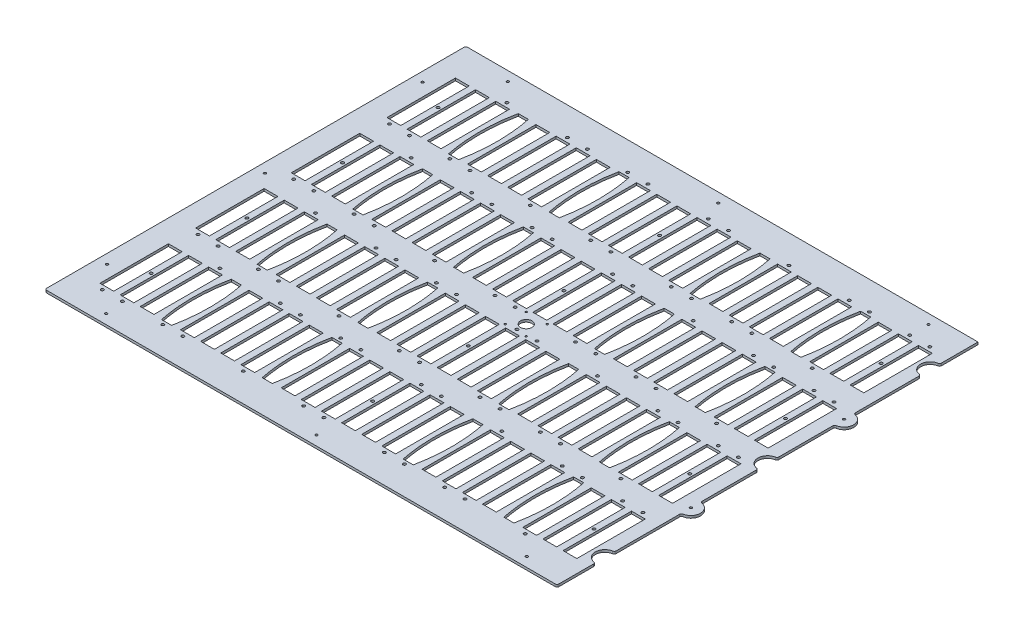
from build123d import *

# Parameters (mm, degrees)
BOSS_EXTRUDE1_DEPTH          = 3.175
SKETCH17_W                   = 18.288
SKETCH17_H                   = 90.932
CUT_EXTRUDE5_DEPTH           = 4.175
F_25_0_1495_DIAMETER_HOLE1_D = 3.7973
FILLET1_R                    = 2.54
F_6_CLEARANCE_HOLE1_D        = 3.7973
F_2_CLEARANCE_HOLE1_D        = 2.4384
SKETCH20_R                   = 7.62
CUT_EXTRUDE6_DEPTH           = 4.175
F_1_8_0_125_DIAMETER_HOLE1_D = 3.175
CUT_EXTRUDE7_DEPTH           = 4.175


with BuildPart() as part:
    # Sketch1 → Boss-Extrude1 (new body)
    with BuildSketch(Plane(origin=(0, 0, 0), x_dir=(1, 0, 0), z_dir=(0, 1, 0))):
        with BuildLine():
            Line((-340.1822, -279.5524), (340.1822, -279.5524))
            Line((340.1822, -279.5524), (340.1822, -228.7524))
            ThreePointArc((340.1822, -228.7524), (327.4822, -216.0524), (340.1822, -203.3524))
            Line((340.1822, -203.3524), (340.1822, -114.4524))
            ThreePointArc((340.1822, -114.4524), (352.8822, -101.7524), (340.1822, -89.0524))
            Line((340.1822, -89.0524), (340.1822, -12.7))
            ThreePointArc((340.1822, -12.7), (327.4822, 0), (340.1822, 12.7))
            Line((340.1822, 12.7), (340.1822, 89.0524))
            ThreePointArc((340.1822, 89.0524), (352.8822, 101.7524), (340.1822, 114.4524))
            Line((340.1822, 114.4524), (340.1822, 203.3524))
            ThreePointArc((340.1822, 203.3524), (327.4822, 216.0524), (340.1822, 228.7524))
            Line((340.1822, 228.7524), (340.1822, 279.5524))
            Line((340.1822, 279.5524), (-340.1822, 279.5524))
            Line((-340.1822, 279.5524), (-340.1822, -279.5524))
        make_face()
    extrude(amount=BOSS_EXTRUDE1_DEPTH)

    # Sketch17 → Cut-Extrude5 (cut, through all)
    with BuildSketch(Plane(origin=(0, 3.175, 0), x_dir=(1, 0, 0), z_dir=(0, 1, 0))):
        with Locations((-274.627008696, 190.6524)):
            Rectangle(SKETCH17_W, SKETCH17_H)
        with Locations((-301.371, 190.6524)):
            Rectangle(SKETCH17_W, SKETCH17_H)
        with Locations((-247.883017391, 190.6524)):
            Rectangle(SKETCH17_W, SKETCH17_H)
        with Locations((-194.395034783, 190.6524)):
            Rectangle(SKETCH17_W, SKETCH17_H)
        with Locations((-167.651043478, 190.6524)):
            Rectangle(SKETCH17_W, SKETCH17_H)
        with Locations((-140.907052174, 190.6524)):
            Rectangle(SKETCH17_W, SKETCH17_H)
        with Locations((-114.16306087, 190.6524)):
            Rectangle(SKETCH17_W, SKETCH17_H)
        with Locations((-60.675078261, 190.6524)):
            Rectangle(SKETCH17_W, SKETCH17_H)
        with Locations((-33.931086957, 190.6524)):
            Rectangle(SKETCH17_W, SKETCH17_H)
        with Locations((-7.187095652, 190.6524)):
            Rectangle(SKETCH17_W, SKETCH17_H)
        with Locations((19.556895652, 190.6524)):
            Rectangle(SKETCH17_W, SKETCH17_H)
        with Locations((46.300886957, 190.6524)):
            Rectangle(SKETCH17_W, SKETCH17_H)
        with Locations((73.044878261, 190.6524)):
            Rectangle(SKETCH17_W, SKETCH17_H)
        with Locations((126.53286087, 190.6524)):
            Rectangle(SKETCH17_W, SKETCH17_H)
        with Locations((153.276852174, 190.6524)):
            Rectangle(SKETCH17_W, SKETCH17_H)
        with Locations((180.020843478, 190.6524)):
            Rectangle(SKETCH17_W, SKETCH17_H)
        with Locations((206.764834783, 190.6524)):
            Rectangle(SKETCH17_W, SKETCH17_H)
        with Locations((260.252817391, 190.6524)):
            Rectangle(SKETCH17_W, SKETCH17_H)
        with Locations((286.996808696, 190.6524)):
            Rectangle(SKETCH17_W, SKETCH17_H)
        with Locations((313.7408, 190.6524)):
            Rectangle(SKETCH17_W, SKETCH17_H)
        with Locations((-274.627008696, 63.5762)):
            Rectangle(SKETCH17_W, SKETCH17_H)
        with Locations((-247.883017391, 63.5762)):
            Rectangle(SKETCH17_W, SKETCH17_H)
        with Locations((-194.395034783, 63.5762)):
            Rectangle(SKETCH17_W, SKETCH17_H)
        with Locations((-167.651043478, 63.5762)):
            Rectangle(SKETCH17_W, SKETCH17_H)
        with Locations((-140.907052174, 63.5762)):
            Rectangle(SKETCH17_W, SKETCH17_H)
        with Locations((-114.16306087, 63.5762)):
            Rectangle(SKETCH17_W, SKETCH17_H)
        with Locations((-60.675078261, 63.5762)):
            Rectangle(SKETCH17_W, SKETCH17_H)
        with Locations((-33.931086957, 63.5762)):
            Rectangle(SKETCH17_W, SKETCH17_H)
        with Locations((-7.187095652, 63.5762)):
            Rectangle(SKETCH17_W, SKETCH17_H)
        with Locations((19.556895652, 63.5762)):
            Rectangle(SKETCH17_W, SKETCH17_H)
        with Locations((46.300886957, 63.5762)):
            Rectangle(SKETCH17_W, SKETCH17_H)
        with Locations((73.044878261, 63.5762)):
            Rectangle(SKETCH17_W, SKETCH17_H)
        with Locations((126.53286087, 63.5762)):
            Rectangle(SKETCH17_W, SKETCH17_H)
        with Locations((153.276852174, 63.5762)):
            Rectangle(SKETCH17_W, SKETCH17_H)
        with Locations((180.020843478, 63.5762)):
            Rectangle(SKETCH17_W, SKETCH17_H)
        with Locations((206.764834783, 63.5762)):
            Rectangle(SKETCH17_W, SKETCH17_H)
        with Locations((260.252817391, 63.5762)):
            Rectangle(SKETCH17_W, SKETCH17_H)
        with Locations((286.996808696, 63.5762)):
            Rectangle(SKETCH17_W, SKETCH17_H)
        with Locations((313.7408, 63.5762)):
            Rectangle(SKETCH17_W, SKETCH17_H)
        with Locations((-274.627008696, -63.5)):
            Rectangle(SKETCH17_W, SKETCH17_H)
        with Locations((-247.883017391, -63.5)):
            Rectangle(SKETCH17_W, SKETCH17_H)
        with Locations((-194.395034783, -63.5)):
            Rectangle(SKETCH17_W, SKETCH17_H)
        with Locations((-167.651043478, -63.5)):
            Rectangle(SKETCH17_W, SKETCH17_H)
        with Locations((-140.907052174, -63.5)):
            Rectangle(SKETCH17_W, SKETCH17_H)
        with Locations((-114.16306087, -63.5)):
            Rectangle(SKETCH17_W, SKETCH17_H)
        with Locations((-60.675078261, -63.5)):
            Rectangle(SKETCH17_W, SKETCH17_H)
        with Locations((-33.931086957, -63.5)):
            Rectangle(SKETCH17_W, SKETCH17_H)
        with Locations((-7.187095652, -63.5)):
            Rectangle(SKETCH17_W, SKETCH17_H)
        with Locations((19.556895652, -63.5)):
            Rectangle(SKETCH17_W, SKETCH17_H)
        with Locations((46.300886957, -63.5)):
            Rectangle(SKETCH17_W, SKETCH17_H)
        with Locations((73.044878261, -63.5)):
            Rectangle(SKETCH17_W, SKETCH17_H)
        with Locations((126.53286087, -63.5)):
            Rectangle(SKETCH17_W, SKETCH17_H)
        with Locations((153.276852174, -63.5)):
            Rectangle(SKETCH17_W, SKETCH17_H)
        with Locations((180.020843478, -63.5)):
            Rectangle(SKETCH17_W, SKETCH17_H)
        with Locations((206.764834783, -63.5)):
            Rectangle(SKETCH17_W, SKETCH17_H)
        with Locations((260.252817391, -63.5)):
            Rectangle(SKETCH17_W, SKETCH17_H)
        with Locations((286.996808696, -63.5)):
            Rectangle(SKETCH17_W, SKETCH17_H)
        with Locations((313.7408, -63.5)):
            Rectangle(SKETCH17_W, SKETCH17_H)
        with Locations((-274.627008696, -190.5762)):
            Rectangle(SKETCH17_W, SKETCH17_H)
        with Locations((-247.883017391, -190.5762)):
            Rectangle(SKETCH17_W, SKETCH17_H)
        with Locations((-194.395034783, -190.5762)):
            Rectangle(SKETCH17_W, SKETCH17_H)
        with Locations((-167.651043478, -190.5762)):
            Rectangle(SKETCH17_W, SKETCH17_H)
        with Locations((-140.907052174, -190.5762)):
            Rectangle(SKETCH17_W, SKETCH17_H)
        with Locations((-114.16306087, -190.5762)):
            Rectangle(SKETCH17_W, SKETCH17_H)
        with Locations((-60.675078261, -190.5762)):
            Rectangle(SKETCH17_W, SKETCH17_H)
        with Locations((-33.931086957, -190.5762)):
            Rectangle(SKETCH17_W, SKETCH17_H)
        with Locations((-7.187095652, -190.5762)):
            Rectangle(SKETCH17_W, SKETCH17_H)
        with Locations((19.556895652, -190.5762)):
            Rectangle(SKETCH17_W, SKETCH17_H)
        with Locations((46.300886957, -190.5762)):
            Rectangle(SKETCH17_W, SKETCH17_H)
        with Locations((73.044878261, -190.5762)):
            Rectangle(SKETCH17_W, SKETCH17_H)
        with Locations((126.53286087, -190.5762)):
            Rectangle(SKETCH17_W, SKETCH17_H)
        with Locations((153.276852174, -190.5762)):
            Rectangle(SKETCH17_W, SKETCH17_H)
        with Locations((180.020843478, -190.5762)):
            Rectangle(SKETCH17_W, SKETCH17_H)
        with Locations((206.764834783, -190.5762)):
            Rectangle(SKETCH17_W, SKETCH17_H)
        with Locations((260.252817391, -190.5762)):
            Rectangle(SKETCH17_W, SKETCH17_H)
        with Locations((286.996808696, -190.5762)):
            Rectangle(SKETCH17_W, SKETCH17_H)
        with Locations((313.7408, -190.5762)):
            Rectangle(SKETCH17_W, SKETCH17_H)
        with Locations((-301.371, 63.5762)):
            Rectangle(SKETCH17_W, SKETCH17_H)
        with Locations((-301.371, -63.5)):
            Rectangle(SKETCH17_W, SKETCH17_H)
        with Locations((-301.371, -190.5762)):
            Rectangle(SKETCH17_W, SKETCH17_H)
    extrude(amount=-CUT_EXTRUDE5_DEPTH, mode=Mode.SUBTRACT)

    # #25 (0.1495) Diameter Hole1 (through all)
    with Locations(Plane(origin=(0, 3.175, 0), x_dir=(1, 0, 0), z_dir=(0, 1, 0))):
        with Locations((-301.523398222, 139.3444), (313.7408, -139.2682), (286.990182686, -139.2682), (260.239565372, -241.8842), (233.488948058, -139.2682), (206.738330744, -139.2682), (179.98771343, -241.8842), (153.237096116, -241.8842), (126.486478802, -139.2682), (99.735861488, -241.8842), (72.985244174, -241.8842), (46.23462686, -139.2682), (19.484009546, -139.2682), (-7.266607768, -241.8842), (-34.017225082, -241.8842), (-60.767842396, -139.2682), (-87.51845971, -139.2682), (-114.269077024, -241.8842), (-141.019694338, -139.2682), (-167.770311652, -139.2682), (-194.520928966, -241.8842), (-221.27154628, -241.8842), (-248.022163594, -139.2682), (-274.772780908, -241.8842), (-301.523398222, -241.8842), (313.7408, -12.192), (286.990182686, -12.192), (260.239565372, -114.808), (233.488948058, -12.192), (206.738330744, -12.192), (179.98771343, -114.808), (153.237096116, -114.808), (126.486478802, -12.192), (99.735861488, -114.808), (72.985244174, -114.808), (46.23462686, -12.192), (19.484009546, -12.192), (-7.266607768, -114.808), (-34.017225082, -114.808), (-60.767842396, -12.192), (-87.51845971, -12.192), (-114.269077024, -114.808), (-141.019694338, -12.192), (-167.770311652, -12.192), (-194.520928966, -114.808), (-221.27154628, -114.808), (-248.022163594, -12.192), (-274.772780908, -114.808), (-301.523398222, -114.808), (313.7408, 114.8842), (286.990182686, 114.8842), (260.239565372, 12.2682), (233.488948058, 114.8842), (206.738330744, 114.8842), (179.98771343, 12.2682), (153.237096116, 12.2682), (126.486478802, 114.8842), (99.735861488, 12.2682), (72.985244174, 12.2682), (46.23462686, 114.8842), (19.484009546, 114.8842), (-7.266607768, 12.2682), (-34.017225082, 12.2682), (-60.767842396, 114.8842), (-87.51845971, 114.8842), (-114.269077024, 12.2682), (-141.019694338, 114.8842), (-167.770311652, 114.8842), (-194.520928966, 12.2682), (-221.27154628, 12.2682), (-248.022163594, 114.8842), (-274.772780908, 12.2682), (-301.523398222, 12.2682), (313.7408, 241.9604), (286.990182686, 241.9604), (260.239565372, 139.3444), (233.488948058, 241.9604), (206.738330744, 241.9604), (179.98771343, 139.3444), (153.237096116, 139.3444), (126.486478802, 241.9604), (99.735861488, 139.3444), (72.985244174, 139.3444), (46.23462686, 241.9604), (19.484009546, 241.9604), (-7.266607768, 139.3444), (-34.017225082, 139.3444), (-60.767842396, 241.9604), (-87.51845971, 241.9604), (-114.269077024, 139.3444), (-141.019694338, 241.9604), (-167.770311652, 241.9604), (-194.520928966, 139.3444), (-221.27154628, 139.3444), (-248.022163594, 241.9604), (-274.772780908, 139.3444)):
            Hole(F_25_0_1495_DIAMETER_HOLE1_D / 2)

    # Fillet1
    fillet1_edges = [part.edges().sort_by_distance(p)[0] for p in [
        (-340.1822, 1.5875, -279.5524),
        (340.1822, 1.5875, -228.7524),
        (340.1822, 1.5875, -203.3524),
        (340.1822, 1.5875, -114.4524),
        (340.1822, 1.5875, -89.0524),
        (340.1822, 1.5875, -12.7),
        (340.1822, 1.5875, 12.7),
        (340.1822, 1.5875, 89.0524),
        (340.1822, 1.5875, 114.4524),
        (340.1822, 1.5875, 203.3524),
        (340.1822, 1.5875, 228.7524),
        (340.1822, 1.5875, 279.5524),
        (-340.1822, 1.5875, 279.5524),
    ]]
    fillet(fillet1_edges, radius=FILLET1_R)

    # #6 Clearance Hole1 (through all)
    with Locations(Plane(origin=(0, 3.175, 0), x_dir=(1, 0, 0), z_dir=(0, 1, 0))):
        with Locations((300.368804348, -190.5762), (-287.999004348, 190.6524), (6.1849, 190.6524), (300.368804348, 190.6524), (-287.999004348, 63.5762), (6.1849, 63.5762), (300.368804348, 63.5762), (-287.999004348, -63.5), (6.1849, -63.5), (300.368804348, -63.5), (-287.999004348, -190.5762), (6.1849, -190.5762)):
            Hole(F_6_CLEARANCE_HOLE1_D / 2)

    # #2 Clearance Hole1 (through all)
    with Locations(Plane(origin=(0, 3.175, 0), x_dir=(1, 0, 0), z_dir=(0, 1, 0))):
        with Locations((33.5661, 14.0081), (5.6261, 14.0081), (5.6261, -13.9319), (33.5661, -13.9319)):
            Hole(F_2_CLEARANCE_HOLE1_D / 2)

    # Sketch20 → Cut-Extrude6 (cut, through all)
    with BuildSketch(Plane(origin=(0, 3.175, 0), x_dir=(1, 0, 0), z_dir=(0, 1, 0))):
        with Locations((19.5961, 0.0381)):
            Circle(SKETCH20_R)
    extrude(amount=-CUT_EXTRUDE6_DEPTH, mode=Mode.SUBTRACT)

    # 1/8 (0.125) Diameter Hole1 (through all)
    with Locations(Plane(origin=(0, 3.175, 0), x_dir=(1, 0, 0), z_dir=(0, 1, 0))):
        with Locations((287.274, -266.8524), (287.274, 266.8524), (7.874, 266.8524), (-271.526, 266.8524), (-327.5584, 209.55), (-327.5584, 0), (-327.5584, -209.55), (-271.526, -266.8524), (7.874, -266.8524), (340.1822, 101.7524), (340.1822, -101.7524)):
            Hole(F_1_8_0_125_DIAMETER_HOLE1_D / 2)

    # Sketch23 → Cut-Extrude7 (cut, through all)
    with BuildSketch(Plane(origin=(0, 3.175, 0), x_dir=(1, 0, 0), z_dir=(0, 1, 0))):
        with BuildLine():
            Line((240.239826087, -144.2212), (226.777826087, -144.2212))
            add(Edge.make_bspline(
                [(226.777826087, -236.9312), (217.379826087, -190.5762), (226.777826087, -144.2212)],
                knots=[0, 0, 0, 1, 1, 1], degree=2))
            Line((226.777826087, -236.9312), (240.239826087, -236.9312))
            add(Edge.make_bspline(
                [(240.239826087, -236.9312), (249.637826087, -190.5762), (240.239826087, -144.2212)],
                knots=[0, 0, 0, 1, 1, 1], degree=2))
        make_face()
        with BuildLine():
            Line((106.503304127, -236.9312), (93.041304127, -236.9312))
            add(Edge.make_bspline(
                [(93.041304127, -236.9312), (83.643304127, -190.5762), (93.041304127, -144.2212)],
                knots=[0, 0, 0, 1, 1, 1], degree=2))
            Line((93.041304127, -144.2212), (106.503304127, -144.2212))
            add(Edge.make_bspline(
                [(106.503304127, -236.9312), (115.901304127, -190.5762), (106.503304127, -144.2212)],
                knots=[0, 0, 0, 1, 1, 1], degree=2))
        make_face()
        with BuildLine():
            Line((-80.727826617, -236.9312), (-94.189826617, -236.9312))
            add(Edge.make_bspline(
                [(-94.189826617, -236.9312), (-103.587826617, -190.5762), (-94.189826617, -144.2212)],
                knots=[0, 0, 0, 1, 1, 1], degree=2))
            Line((-94.189826617, -144.2212), (-80.727826617, -144.2212))
            add(Edge.make_bspline(
                [(-80.727826617, -236.9312), (-71.329826617, -190.5762), (-80.727826617, -144.2212)],
                knots=[0, 0, 0, 1, 1, 1], degree=2))
        make_face()
        with BuildLine():
            Line((-214.464348577, -236.9312), (-227.926348577, -236.9312))
            add(Edge.make_bspline(
                [(-227.926348577, -236.9312), (-237.324348577, -190.5762), (-227.926348577, -144.2212)],
                knots=[0, 0, 0, 1, 1, 1], degree=2))
            Line((-227.926348577, -144.2212), (-214.464348577, -144.2212))
            add(Edge.make_bspline(
                [(-214.464348577, -236.9312), (-205.066348577, -190.5762), (-214.464348577, -144.2212)],
                knots=[0, 0, 0, 1, 1, 1], degree=2))
        make_face()
        with BuildLine():
            Line((240.239826087, -109.855), (226.777826087, -109.855))
            add(Edge.make_bspline(
                [(226.777826087, -109.855), (217.379826087, -63.5), (226.777826087, -17.145)],
                knots=[0, 0, 0, 1, 1, 1], degree=2))
            Line((226.777826087, -17.145), (240.239826087, -17.145))
            add(Edge.make_bspline(
                [(240.239826087, -109.855), (249.637826087, -63.5), (240.239826087, -17.145)],
                knots=[0, 0, 0, 1, 1, 1], degree=2))
        make_face()
        with BuildLine():
            Line((106.503304127, -109.855), (93.041304127, -109.855))
            add(Edge.make_bspline(
                [(93.041304127, -109.855), (83.643304127, -63.5), (93.041304127, -17.145)],
                knots=[0, 0, 0, 1, 1, 1], degree=2))
            Line((93.041304127, -17.145), (106.503304127, -17.145))
            add(Edge.make_bspline(
                [(106.503304127, -109.855), (115.901304127, -63.5), (106.503304127, -17.145)],
                knots=[0, 0, 0, 1, 1, 1], degree=2))
        make_face()
        with BuildLine():
            Line((-80.727826617, -109.855), (-94.189826617, -109.855))
            add(Edge.make_bspline(
                [(-94.189826617, -109.855), (-103.587826617, -63.5), (-94.189826617, -17.145)],
                knots=[0, 0, 0, 1, 1, 1], degree=2))
            Line((-94.189826617, -17.145), (-80.727826617, -17.145))
            add(Edge.make_bspline(
                [(-80.727826617, -109.855), (-71.329826617, -63.5), (-80.727826617, -17.145)],
                knots=[0, 0, 0, 1, 1, 1], degree=2))
        make_face()
        with BuildLine():
            Line((-214.464348577, -109.855), (-227.926348577, -109.855))
            add(Edge.make_bspline(
                [(-227.926348577, -109.855), (-237.324348577, -63.5), (-227.926348577, -17.145)],
                knots=[0, 0, 0, 1, 1, 1], degree=2))
            Line((-227.926348577, -17.145), (-214.464348577, -17.145))
            add(Edge.make_bspline(
                [(-214.464348577, -109.855), (-205.066348577, -63.5), (-214.464348577, -17.145)],
                knots=[0, 0, 0, 1, 1, 1], degree=2))
        make_face()
        with BuildLine():
            Line((240.239826087, 17.2212), (226.777826087, 17.2212))
            add(Edge.make_bspline(
                [(226.777826087, 17.2212), (217.379826087, 63.5762), (226.777826087, 109.9312)],
                knots=[0, 0, 0, 1, 1, 1], degree=2))
            Line((226.777826087, 109.9312), (240.239826087, 109.9312))
            add(Edge.make_bspline(
                [(240.239826087, 17.2212), (249.637826087, 63.5762), (240.239826087, 109.9312)],
                knots=[0, 0, 0, 1, 1, 1], degree=2))
        make_face()
        with BuildLine():
            Line((106.503304127, 17.2212), (93.041304127, 17.2212))
            add(Edge.make_bspline(
                [(93.041304127, 17.2212), (83.643304127, 63.5762), (93.041304127, 109.9312)],
                knots=[0, 0, 0, 1, 1, 1], degree=2))
            Line((93.041304127, 109.9312), (106.503304127, 109.9312))
            add(Edge.make_bspline(
                [(106.503304127, 17.2212), (115.901304127, 63.5762), (106.503304127, 109.9312)],
                knots=[0, 0, 0, 1, 1, 1], degree=2))
        make_face()
        with BuildLine():
            Line((-80.727826617, 17.2212), (-94.189826617, 17.2212))
            add(Edge.make_bspline(
                [(-94.189826617, 17.2212), (-103.587826617, 63.5762), (-94.189826617, 109.9312)],
                knots=[0, 0, 0, 1, 1, 1], degree=2))
            Line((-94.189826617, 109.9312), (-80.727826617, 109.9312))
            add(Edge.make_bspline(
                [(-80.727826617, 17.2212), (-71.329826617, 63.5762), (-80.727826617, 109.9312)],
                knots=[0, 0, 0, 1, 1, 1], degree=2))
        make_face()
        with BuildLine():
            Line((-214.464348577, 17.2212), (-227.926348577, 17.2212))
            add(Edge.make_bspline(
                [(-227.926348577, 17.2212), (-237.324348577, 63.5762), (-227.926348577, 109.9312)],
                knots=[0, 0, 0, 1, 1, 1], degree=2))
            Line((-227.926348577, 109.9312), (-214.464348577, 109.9312))
            add(Edge.make_bspline(
                [(-214.464348577, 17.2212), (-205.066348577, 63.5762), (-214.464348577, 109.9312)],
                knots=[0, 0, 0, 1, 1, 1], degree=2))
        make_face()
        with BuildLine():
            Line((240.239826087, 144.2974), (226.777826087, 144.2974))
            add(Edge.make_bspline(
                [(226.777826087, 144.2974), (217.379826087, 190.6524), (226.777826087, 237.0074)],
                knots=[0, 0, 0, 1, 1, 1], degree=2))
            Line((226.777826087, 237.0074), (240.239826087, 237.0074))
            add(Edge.make_bspline(
                [(240.239826087, 144.2974), (249.637826087, 190.6524), (240.239826087, 237.0074)],
                knots=[0, 0, 0, 1, 1, 1], degree=2))
        make_face()
        with BuildLine():
            Line((106.503304127, 144.2974), (93.041304127, 144.2974))
            add(Edge.make_bspline(
                [(93.041304127, 144.2974), (83.643304127, 190.6524), (93.041304127, 237.0074)],
                knots=[0, 0, 0, 1, 1, 1], degree=2))
            Line((93.041304127, 237.0074), (106.503304127, 237.0074))
            add(Edge.make_bspline(
                [(106.503304127, 144.2974), (115.901304127, 190.6524), (106.503304127, 237.0074)],
                knots=[0, 0, 0, 1, 1, 1], degree=2))
        make_face()
        with BuildLine():
            Line((-80.727826617, 144.2974), (-94.189826617, 144.2974))
            add(Edge.make_bspline(
                [(-94.189826617, 144.2974), (-103.587826617, 190.6524), (-94.189826617, 237.0074)],
                knots=[0, 0, 0, 1, 1, 1], degree=2))
            Line((-94.189826617, 237.0074), (-80.727826617, 237.0074))
            add(Edge.make_bspline(
                [(-80.727826617, 144.2974), (-71.329826617, 190.6524), (-80.727826617, 237.0074)],
                knots=[0, 0, 0, 1, 1, 1], degree=2))
        make_face()
        with BuildLine():
            Line((-214.464348577, 144.2974), (-227.926348577, 144.2974))
            add(Edge.make_bspline(
                [(-227.926348577, 144.2974), (-237.324348577, 190.6524), (-227.926348577, 237.0074)],
                knots=[0, 0, 0, 1, 1, 1], degree=2))
            Line((-227.926348577, 237.0074), (-214.464348577, 237.0074))
            add(Edge.make_bspline(
                [(-214.464348577, 144.2974), (-205.066348577, 190.6524), (-214.464348577, 237.0074)],
                knots=[0, 0, 0, 1, 1, 1], degree=2))
        make_face()
    extrude(amount=-CUT_EXTRUDE7_DEPTH, mode=Mode.SUBTRACT)


solid = part.part
